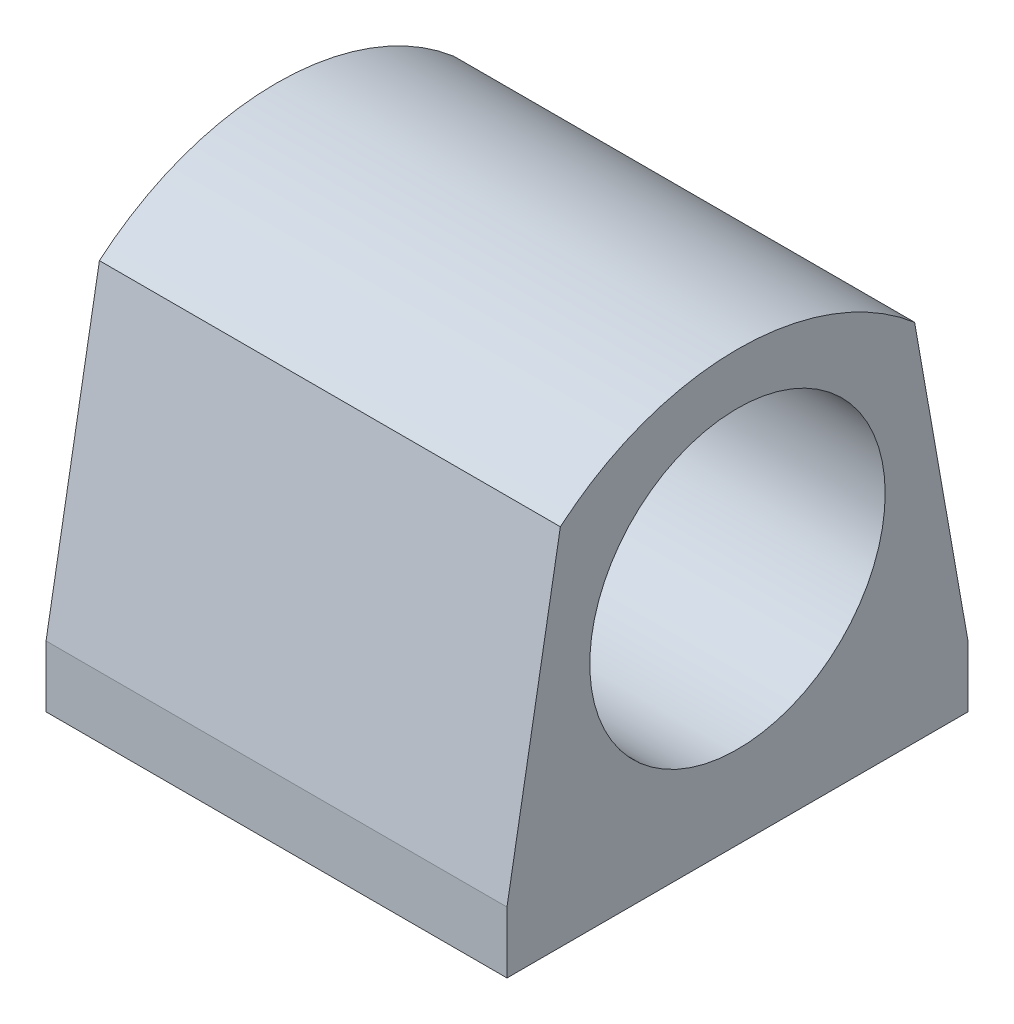
from build123d import *

# Parameters (mm, degrees)
SKETCH2_W           = 38.1
SKETCH2_H           = 38.1
BOSS_EXTRUDE1_DEPTH = 5.08
BOSS_EXTRUDE3_DEPTH = 38.1
SKETCH5_R           = 12.2084592
CUT_EXTRUDE1_DEPTH  = 39.1
BOSS_EXTRUDE4_DEPTH = 5.08


with BuildPart() as part:
    # Sketch2 → Boss-Extrude1 (new body)
    with BuildSketch(Plane(origin=(0, 0, 0), x_dir=(1, 0, 0), z_dir=(0, 1, 0))):
        Rectangle(SKETCH2_W, SKETCH2_H)
    extrude(amount=BOSS_EXTRUDE1_DEPTH)

    # Sketch3 → Boss-Extrude3 (add, through all)
    with BuildSketch(Plane(origin=(19.05, 0, 0), x_dir=(0, 0, -1), z_dir=(1, 0, 0))):
        with BuildLine():
            Line((-19.05, 5.08), (-14.639336287, 30.094116927))
            ThreePointArc((-14.639336287, 30.094116927), (0, 35.484404044), (14.639336287, 30.094116927))
            Line((14.639336287, 30.094116927), (19.05, 5.08))
            Line((19.05, 5.08), (-19.05, 5.08))
        make_face()
    extrude(amount=-BOSS_EXTRUDE3_DEPTH)

    # Sketch5 → Cut-Extrude1 (cut, through all)
    with BuildSketch(Plane(origin=(19.05, 0, 0), x_dir=(0, 0, -1), z_dir=(1, 0, 0))):
        with Locations((0, 19.05)):
            Circle(SKETCH5_R)
    extrude(amount=-CUT_EXTRUDE1_DEPTH, mode=Mode.SUBTRACT)

    # Sketch6 → Boss-Extrude4 (add)
    with BuildSketch(Plane(origin=(0, 0, -19.05), x_dir=(-1, 0, 0), z_dir=(0, 0, -1))):
        Polygon((19.05, 0), (19.05, -19.05), (0, 0), align=None)
    extrude(amount=-BOSS_EXTRUDE4_DEPTH)


solid = part.part
